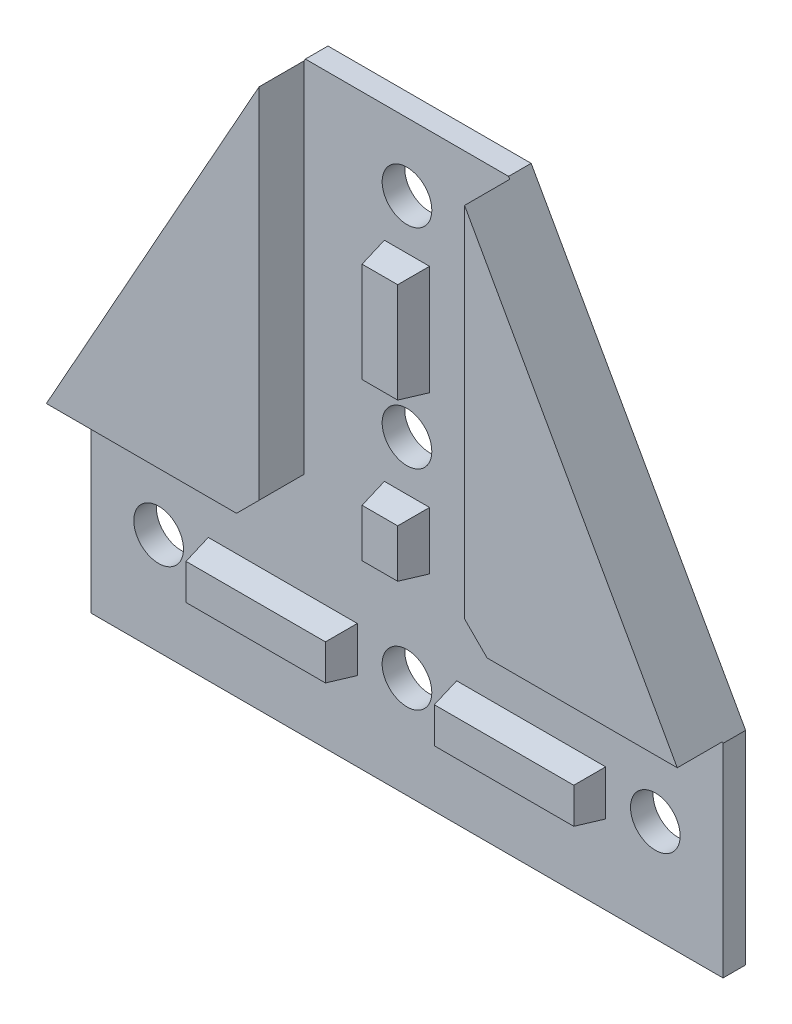
from build123d import *

# Parameters (mm, degrees)
ESQUISSE1_R        = 5.5
BOSS_EXTRU_1_DEPTH = 5
ESQUISSE2_W        = 33
ESQUISSE2_H        = 10
ESQUISSE2_W_2      = 10
ESQUISSE2_H_2      = 24.25
ESQUISSE2_H_3      = 12.75
BOSS_EXTRU_2_DEPTH = 6
D_POUILLE1_ANGLE   = 10
BOSS_EXTRU_3_DEPTH = 10
CHANFREIN1_SIZE    = 5


with BuildPart() as part:
    # Esquisse1 → Boss.-Extru.1 (new body)
    with BuildSketch(Plane.XY):
        Polygon((-22.5, 75.232443508), (22.5, 75.232443508), (70, -9.767556492), (70, -54.767556492), (-70, -54.767556492), (-70, -9.767556492), align=None)
        with Locations((0, 60.232443508)):
            Circle(ESQUISSE1_R, mode=Mode.SUBTRACT)
        with Locations((0, 13.982443508)):
            Circle(ESQUISSE1_R, mode=Mode.SUBTRACT)
        with Locations((0, -32.267556492)):
            Circle(ESQUISSE1_R, mode=Mode.SUBTRACT)
        with Locations((-55, -32.267556492)):
            Circle(ESQUISSE1_R, mode=Mode.SUBTRACT)
        with Locations((55, -32.267556492)):
            Circle(ESQUISSE1_R, mode=Mode.SUBTRACT)
    extrude(amount=BOSS_EXTRU_1_DEPTH)

    # Esquisse2 → Boss.-Extru.2 (add)
    with BuildSketch(Plane.XY.offset(5)):
        with Locations((-27.5, -32.267556492)):
            Rectangle(ESQUISSE2_W, ESQUISSE2_H)
        with Locations((27.5, -32.267556492)):
            Rectangle(ESQUISSE2_W, ESQUISSE2_H)
        with Locations((0, 37.107443508)):
            Rectangle(ESQUISSE2_W_2, ESQUISSE2_H_2)
        with Locations((0, -3.392556492)):
            Rectangle(ESQUISSE2_W_2, ESQUISSE2_H_3)
    extrude(amount=BOSS_EXTRU_2_DEPTH)

    # Dépouille1
    d_pouille1_faces = [part.faces().sort_by_distance(p)[0] for p in [
        (44, -32.267556492, 8),
        (27.5, -27.267556492, 8),
        (-11, -32.267556492, 8),
        (-27.5, -27.267556492, 8),
        (0, 2.982443508, 8),
        (5, -3.392556492, 8),
        (0, 49.232443508, 8),
        (5, 37.107443508, 8),
        (-5, 37.107443508, 8),
        (0, 24.982443508, 8),
        (11, -32.267556492, 8),
        (-44, -32.267556492, 8),
        (-5, -3.392556492, 8),
        (-27.5, -37.267556492, 8),
        (27.5, -37.267556492, 8),
        (0, -9.767556492, 8),
    ]]
    draft(d_pouille1_faces, Plane.XY.offset(5), D_POUILLE1_ANGLE)

    # Esquisse3 → Boss.-Extru.3 (add)
    with BuildSketch(Plane.XY.offset(5)):
        Polygon((-22.75, 74.785075087), (-22.75, -9.517556492), (-69.860294118, -9.517556492), align=None)
        Polygon((22.75, -9.517556492), (69.860294118, -9.517556492), (22.75, 74.785075087), align=None)
    extrude(amount=BOSS_EXTRU_3_DEPTH)

    # Chanfrein1
    chanfrein1_edges = [part.edges().sort_by_distance(p)[0] for p in [
        (-22.75, -9.517556492, 10),
        (22.75, -9.517556492, 10),
    ]]
    chamfer(chanfrein1_edges, length=CHANFREIN1_SIZE)


solid = part.part
